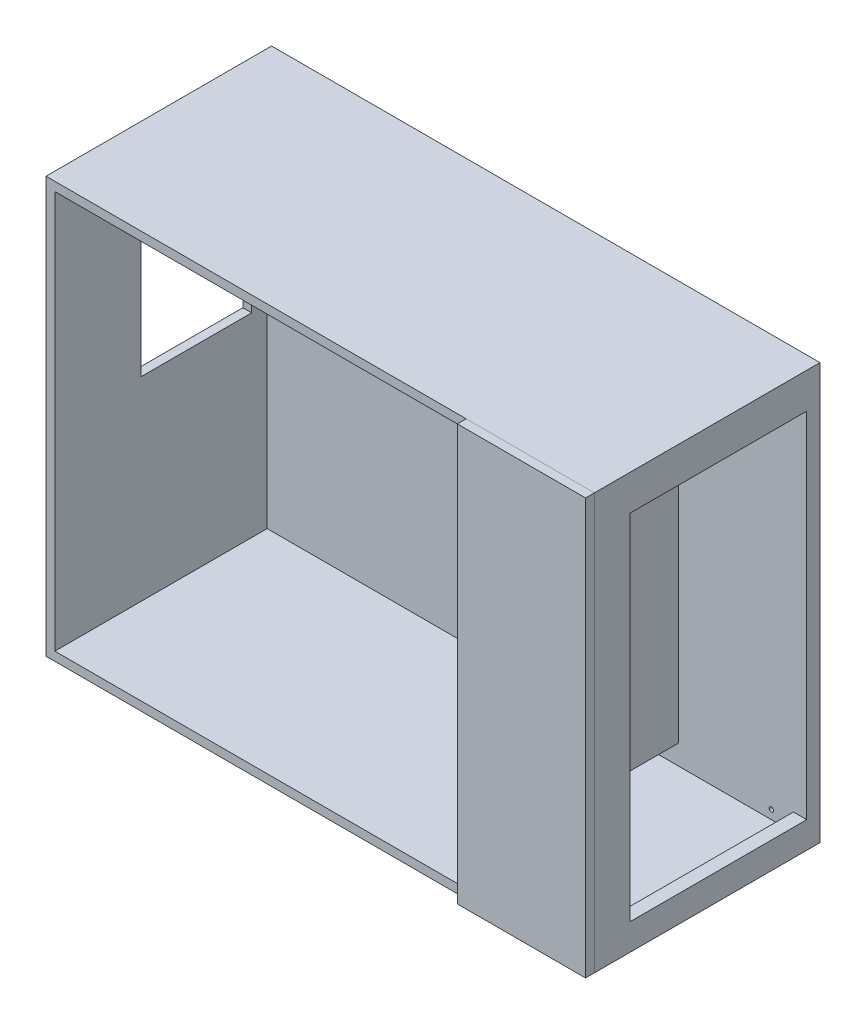
from build123d import *

# Parameters (mm, degrees)
CROQUIS1_W              = 1300
CROQUIS1_H              = 510
SALIENTE_EXTRUIR1_DEPTH = 1200
CROQUIS2_W              = 910
CROQUIS2_H              = 900
CORTAR_EXTRUIR1_DEPTH   = 480
CROQUIS3_W              = 250
CROQUIS3_H              = 400
CORTAR_EXTRUIR2_DEPTH   = 70
CROQUIS4_W              = 260
CROQUIS4_H              = 900
CORTAR_EXTRUIR3_DEPTH   = 480
CROQUIS5_W              = 400
CROQUIS5_H              = 800
CORTAR_EXTRUIR4_DEPTH   = 320
CROQUIS6_W              = 130
CROQUIS6_H              = 45
CORTAR_EXTRUIR5_DEPTH   = 230
CROQUIS7_W              = 350
CROQUIS7_H              = 1200
SALIENTE_EXTRUIR2_DEPTH = 20
CROQUIS9_W              = 510
CROQUIS9_H              = 90
CORTAR_EXTRUIR6_DEPTH   = 1440
CORTAR_EXTRUIR7_DEPTH   = 1440
CROQUIS12_W             = 290
CROQUIS12_H             = 90
CORTAR_EXTRUIR8_DEPTH   = 1440
CROQUIS14_W             = 1303.36123447
CROQUIS14_H             = 170
CORTAR_EXTRUIR9_DEPTH   = 1440
CROQUIS15_W             = 290
CROQUIS15_H             = 70
CORTAR_EXTRUIR10_DEPTH  = 1440
CROQUIS16_W             = 290
CROQUIS16_H             = 100
CORTAR_EXTRUIR11_DEPTH  = 1440
CROQUIS17_R             = 5
CORTAR_EXTRUIR12_DEPTH  = 30


with BuildPart() as part:
    # Croquis1 → Saliente-Extruir1 (new body)
    with BuildSketch(Plane(origin=(0, 0, 0), x_dir=(1, 0, 0), z_dir=(0, 1, 0))):
        Rectangle(CROQUIS1_W, CROQUIS1_H)
    extrude(amount=SALIENTE_EXTRUIR1_DEPTH)

    # Croquis2 → Cortar-Extruir1 (cut)
    with BuildSketch(Plane.XY.offset(255)):
        with Locations((-175, 560)):
            Rectangle(CROQUIS2_W, CROQUIS2_H)
    extrude(amount=-CORTAR_EXTRUIR1_DEPTH, mode=Mode.SUBTRACT)

    # Croquis3 → Cortar-Extruir2 (cut)
    with BuildSketch(Plane.ZY.offset(650)):
        with Locations((-65, 750)):
            Rectangle(CROQUIS3_W, CROQUIS3_H)
    extrude(amount=-CORTAR_EXTRUIR2_DEPTH, mode=Mode.SUBTRACT)

    # Croquis4 → Cortar-Extruir3 (cut)
    with BuildSketch(Plane.XY.offset(255)):
        with Locations((430, 560)):
            Rectangle(CROQUIS4_W, CROQUIS4_H)
    extrude(amount=-CORTAR_EXTRUIR3_DEPTH, mode=Mode.SUBTRACT)

    # Croquis5 → Cortar-Extruir4 (cut)
    with BuildSketch(Plane(origin=(650, 0, 0), x_dir=(0, 0, -1), z_dir=(1, 0, 0))):
        with Locations((25, 550)):
            Rectangle(CROQUIS5_W, CROQUIS5_H)
    extrude(amount=-CORTAR_EXTRUIR4_DEPTH, mode=Mode.SUBTRACT)

    # Croquis6 → Cortar-Extruir5 (cut)
    with BuildSketch(Plane.ZY.offset(-280)):
        with Locations((-160, 132.5)):
            Rectangle(CROQUIS6_W, CROQUIS6_H)
    extrude(amount=-CORTAR_EXTRUIR5_DEPTH, mode=Mode.SUBTRACT)

    # Croquis9 → Cortar-Extruir6 (cut)
    with BuildSketch(Plane.ZY.offset(650)):
        with Locations((0, 45)):
            Rectangle(CROQUIS9_W, CROQUIS9_H)
    extrude(amount=-CORTAR_EXTRUIR6_DEPTH, mode=Mode.SUBTRACT)


with BuildPart() as body_2:
    # Croquis7 → Saliente-Extruir2 (new body)
    with BuildSketch(Plane.XY.offset(255)):
        with Locations((475, 600)):
            Rectangle(CROQUIS7_W, CROQUIS7_H)
    extrude(amount=SALIENTE_EXTRUIR2_DEPTH)


with BuildPart() as cortar_extruir7_tool:
    # Croquis11 → Cortar-Extruir7 (new body)
    with BuildSketch(Plane.XY.offset(275)):
        Polygon((650, 1200), (590, 1200), (590, 90), (590, 0), (650, 0), align=None)
    extrude(amount=-CORTAR_EXTRUIR7_DEPTH)


with BuildPart() as part_1:
    add(part.part)

    # Cortar-Extruir7: cut by cortar_extruir7_tool
    add(cortar_extruir7_tool.part, mode=Mode.SUBTRACT)

    # Croquis14 → Cortar-Extruir9 (cut)
    with BuildSketch(Plane.XY.offset(255)):
        with Locations((1.680617235, 1115)):
            Rectangle(CROQUIS14_W, CROQUIS14_H)
    extrude(amount=-CORTAR_EXTRUIR9_DEPTH, mode=Mode.SUBTRACT)

    # Croquis17 → Cortar-Extruir12 (cut)
    with BuildSketch(Plane(origin=(0, 0, -255), x_dir=(-1, 0, 0), z_dir=(0, 0, -1))):
        with Locations((-510, 130)):
            Circle(CROQUIS17_R)
    extrude(amount=-CORTAR_EXTRUIR12_DEPTH, mode=Mode.SUBTRACT)


with BuildPart() as body_2_1:
    add(body_2.part)

    # Cortar-Extruir7: cut by cortar_extruir7_tool
    add(cortar_extruir7_tool.part, mode=Mode.SUBTRACT)

    # Croquis12 → Cortar-Extruir8 (cut)
    with BuildSketch(Plane.XY.offset(275)):
        with Locations((445, 45)):
            Rectangle(CROQUIS12_W, CROQUIS12_H)
    extrude(amount=-CORTAR_EXTRUIR8_DEPTH, mode=Mode.SUBTRACT)

    # Croquis15 → Cortar-Extruir10 (cut)
    with BuildSketch(Plane.XY.offset(275)):
        with Locations((445, 1165)):
            Rectangle(CROQUIS15_W, CROQUIS15_H)
    extrude(amount=-CORTAR_EXTRUIR10_DEPTH, mode=Mode.SUBTRACT)

    # Croquis16 → Cortar-Extruir11 (cut)
    with BuildSketch(Plane.XY.offset(275)):
        with Locations((445, 1080)):
            Rectangle(CROQUIS16_W, CROQUIS16_H)
    extrude(amount=-CORTAR_EXTRUIR11_DEPTH, mode=Mode.SUBTRACT)


solid = Compound([part_1.part, body_2_1.part])
